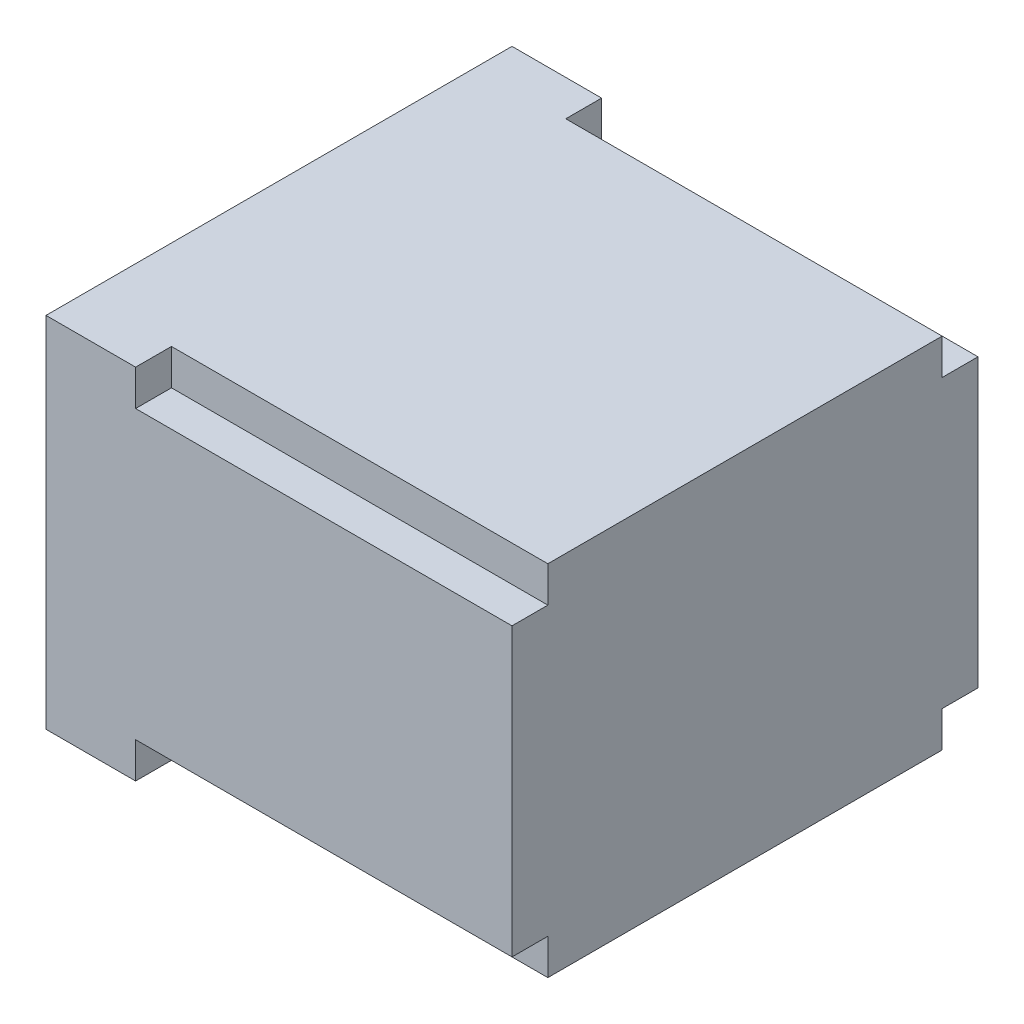
from build123d import *

# Parameters (mm, degrees)
SKETCH2_W           = 130
SKETCH2_H           = 130
BOSS_EXTRUDE1_DEPTH = 100
SKETCH3_W           = 104
SKETCH3_H           = 74
CUT_EXTRUDE1_DEPTH  = 127
SKETCH4_W           = 10
SKETCH4_H           = 10
CUT_EXTRUDE3_DEPTH  = 105
SKETCH5_W           = 104
SKETCH5_H           = 10
CUT_EXTRUDE4_DEPTH  = 127
SKETCH6_W           = 10
SKETCH6_H           = 74
CUT_EXTRUDE5_DEPTH  = 127
SKETCH7_R           = 1.75
CUT_EXTRUDE6_DEPTH  = 20
SKETCH8_W           = 3
SKETCH8_H           = 3
CUT_EXTRUDE7_DEPTH  = 5


with BuildPart() as part:
    # Sketch2 → Boss-Extrude1 (new body)
    with BuildSketch(Plane(origin=(0, 0, 0), x_dir=(1, 0, 0), z_dir=(0, 1, 0))):
        with Locations((65, 65)):
            Rectangle(SKETCH2_W, SKETCH2_H)
    extrude(amount=BOSS_EXTRUDE1_DEPTH)

    # Sketch3 → Cut-Extrude1 (cut)
    with BuildSketch(Plane.ZY):
        with Locations((-65, 50)):
            Rectangle(SKETCH3_W, SKETCH3_H)
    extrude(amount=-CUT_EXTRUDE1_DEPTH, mode=Mode.SUBTRACT)

    # Sketch4 → Cut-Extrude3 (cut)
    with BuildSketch(Plane(origin=(130, 0, 0), x_dir=(0, 0, -1), z_dir=(1, 0, 0))):
        with Locations((5, 95)):
            Rectangle(SKETCH4_W, SKETCH4_H)
        with Locations((125, 95)):
            Rectangle(SKETCH4_W, SKETCH4_H)
        with Locations((5, 5)):
            Rectangle(SKETCH4_W, SKETCH4_H)
        with Locations((125, 5)):
            Rectangle(SKETCH4_W, SKETCH4_H)
    extrude(amount=-CUT_EXTRUDE3_DEPTH, mode=Mode.SUBTRACT)

    # Sketch5 → Cut-Extrude4 (cut)
    with BuildSketch(Plane.ZY):
        with Locations((-65, 92)):
            Rectangle(SKETCH5_W, SKETCH5_H)
        with Locations((-65, 8)):
            Rectangle(SKETCH5_W, SKETCH5_H)
    extrude(amount=-CUT_EXTRUDE4_DEPTH, mode=Mode.SUBTRACT)

    # Sketch6 → Cut-Extrude5 (cut)
    with BuildSketch(Plane.ZY):
        with Locations((-122, 50)):
            Rectangle(SKETCH6_W, SKETCH6_H)
        with Locations((-8, 50)):
            Rectangle(SKETCH6_W, SKETCH6_H)
    extrude(amount=-CUT_EXTRUDE5_DEPTH, mode=Mode.SUBTRACT)

    # Sketch7 → Cut-Extrude6 (cut)
    with BuildSketch(Plane.ZY):
        with Locations((-124, 94)):
            Circle(SKETCH7_R)
        with Locations((-6, 94)):
            Circle(SKETCH7_R)
        with Locations((-124, 6)):
            Circle(SKETCH7_R)
        with Locations((-6, 6)):
            Circle(SKETCH7_R)
    extrude(amount=-CUT_EXTRUDE6_DEPTH, mode=Mode.SUBTRACT)

    # Sketch8 → Cut-Extrude7 (cut)
    with BuildSketch(Plane.ZY):
        with Locations((-118.5, 88.5)):
            Rectangle(SKETCH8_W, SKETCH8_H)
        with Locations((-11.5, 88.5)):
            Rectangle(SKETCH8_W, SKETCH8_H)
        with Locations((-118.5, 11.5)):
            Rectangle(SKETCH8_W, SKETCH8_H)
        with Locations((-11.5, 11.5)):
            Rectangle(SKETCH8_W, SKETCH8_H)
    extrude(amount=-CUT_EXTRUDE7_DEPTH, mode=Mode.SUBTRACT)


solid = part.part
